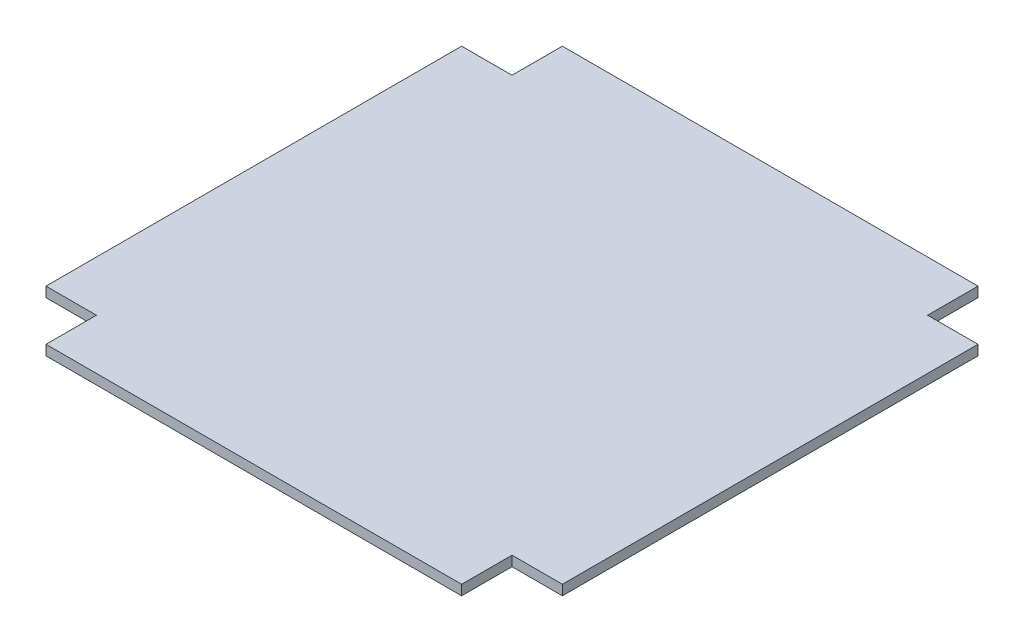
from build123d import *

# Parameters (mm, degrees)
SKETCH1_W           = 42
SKETCH1_H           = 42
BOSS_EXTRUDE1_DEPTH = 4


with BuildPart() as part:
    # Sketch1 → Boss-Extrude1 (new body)
    with BuildSketch(Plane(origin=(0, 0, 0), x_dir=(1, 0, 0), z_dir=(0, 1, 0))):
        Polygon((-82.9, -82.9), (-82.9, -103), (82.9, -103), (82.9, -82.9), (103, -82.9), (103, 82.9), (82.9, 82.9), (82.9, 103), (-82.9, 103), (-82.9, 82.9), (-103, 82.9), (-103, -82.9), align=None)
        Rectangle(SKETCH1_W, SKETCH1_H, mode=Mode.SUBTRACT)
        Rectangle(SKETCH1_W, SKETCH1_H)
    extrude(amount=BOSS_EXTRUDE1_DEPTH)


solid = part.part
